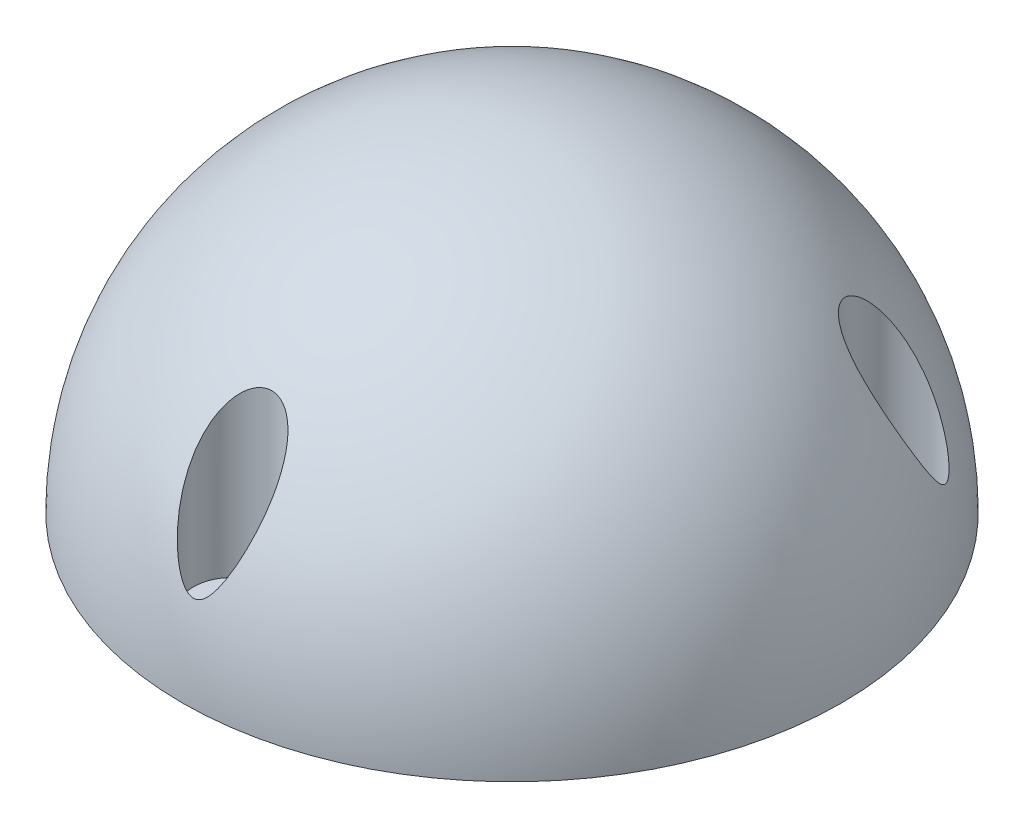
from build123d import *

# Parameters (mm, degrees)
CUT_EXTRUDE_START   = -5
SKETCH_2_R          = 3.5
CUT_EXTRUDE_6_DEPTH = 40
SKETCH_2_9_R        = 2
CUT_EXTRUDE_7_DEPTH = 40


with BuildPart() as part:
    # 스케치1 → 회전1 (revolve)
    with BuildSketch(Plane.XY):
        with BuildLine():
            ThreePointArc((0, 29.5), (-20.859650045, 20.859650045), (-29.5, 0))
            Line((-29.5, 0), (0, 0))
            Line((0, 0), (0, 29.5))
        make_face()
    revolve(axis=Axis((0, 0, 0), (0, 1, 0)))

    # 스케치2 → 컷-돌출6 (cut)
    with BuildSketch(Plane.XZ.offset(CUT_EXTRUDE_START)):
        with Locations((0, 25)):
            Circle(SKETCH_2_R)
        with Locations((21.650635095, -12.5)):
            Circle(SKETCH_2_R)
        with Locations((-21.650635095, -12.5)):
            Circle(SKETCH_2_R)
    extrude(amount=-CUT_EXTRUDE_6_DEPTH, mode=Mode.SUBTRACT)

    # 스케치2<9> → 컷-돌출7 (cut)
    with BuildSketch(Plane.XZ):
        with Locations((0, 25)):
            Circle(SKETCH_2_9_R)
        with Locations((21.650635095, -12.5)):
            Circle(SKETCH_2_9_R)
        with Locations((-21.650635095, -12.5)):
            Circle(SKETCH_2_9_R)
    extrude(amount=-CUT_EXTRUDE_7_DEPTH, mode=Mode.SUBTRACT)


solid = part.part
